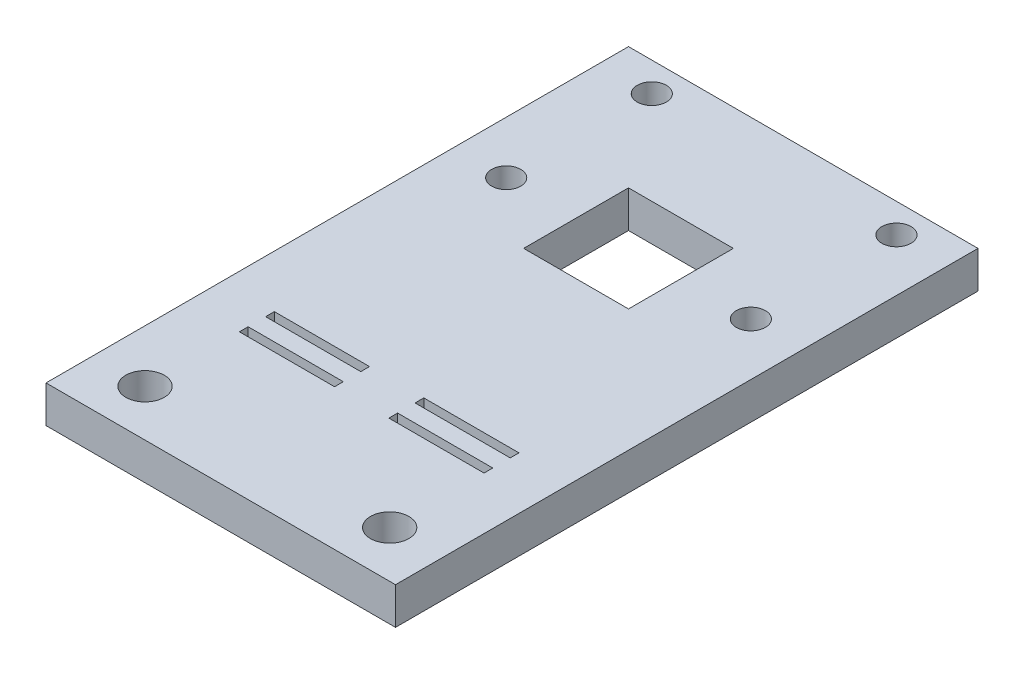
from build123d import *

# Parameters (mm, degrees)
SKETCH1_W           = 30
SKETCH1_H           = 50
SKETCH1_R           = 1.25
SKETCH1_R_2         = 1.65
SKETCH1_W_2         = 8.169972816
SKETCH1_H_2         = 0.75
SKETCH1_W_3         = 9
SKETCH1_H_3         = 9
BOSS_EXTRUDE1_DEPTH = 3.175


with BuildPart() as part:
    # Sketch1 → Boss-Extrude1 (new body)
    with BuildSketch(Plane(origin=(0, 0, 0), x_dir=(1, 0, 0), z_dir=(0, 1, 0))):
        Rectangle(SKETCH1_W, SKETCH1_H)
        with Locations((-10.5, 22.5)):
            Circle(SKETCH1_R, mode=Mode.SUBTRACT)
        with Locations((10.5, 22.5)):
            Circle(SKETCH1_R, mode=Mode.SUBTRACT)
        with Locations((10.5, 10)):
            Circle(SKETCH1_R, mode=Mode.SUBTRACT)
        with Locations((-10.5, 10)):
            Circle(SKETCH1_R, mode=Mode.SUBTRACT)
        with Locations((-10.5, -21)):
            Circle(SKETCH1_R_2, mode=Mode.SUBTRACT)
        with Locations((10.5, -21)):
            Circle(SKETCH1_R_2, mode=Mode.SUBTRACT)
        with Locations((6.415013592, -10.275512249)):
            Rectangle(SKETCH1_W_2, SKETCH1_H_2, mode=Mode.SUBTRACT)
        with Locations((-6.415013592, -12.525512249)):
            Rectangle(SKETCH1_W_2, SKETCH1_H_2, mode=Mode.SUBTRACT)
        with Locations((-6.415013592, -10.275512249)):
            Rectangle(SKETCH1_W_2, SKETCH1_H_2, mode=Mode.SUBTRACT)
        with Locations((6.415013592, -12.525512249)):
            Rectangle(SKETCH1_W_2, SKETCH1_H_2, mode=Mode.SUBTRACT)
        with Locations((0, 10)):
            Rectangle(SKETCH1_W_3, SKETCH1_H_3, mode=Mode.SUBTRACT)
    extrude(amount=BOSS_EXTRUDE1_DEPTH)


solid = part.part
